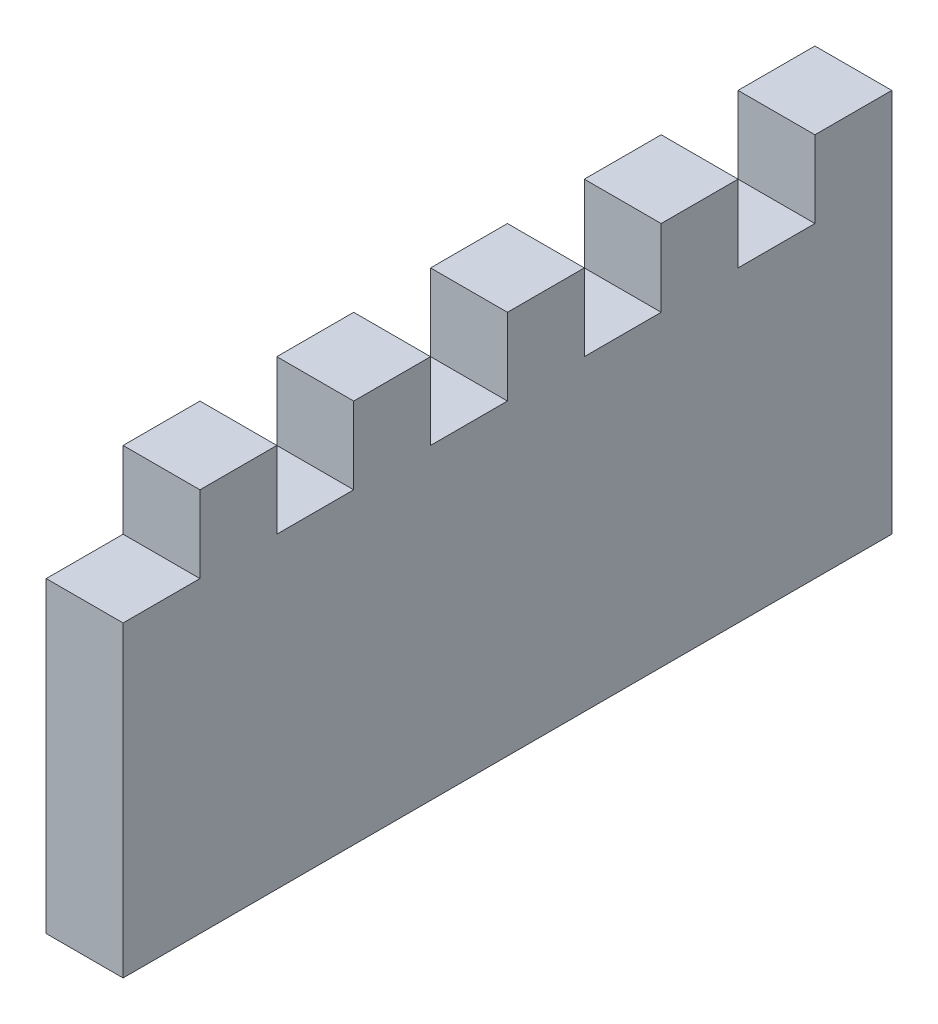
from build123d import *

# Parameters (mm, degrees)
ESQUISSE1_W                = 100
ESQUISSE1_H                = 50
BOSS_EXTRU_1_DEPTH         = 10
ESQUISSE2_W                = 10
ESQUISSE2_H                = 10
ENL_V_MAT_EXTRU_1_DEPTH    = 10
R_P_TITION_LIN_AIRE1_COUNT = 5
R_P_TITION_LIN_AIRE1_PITCH = 20


with BuildPart() as part:
    # Esquisse1 → Boss.-Extru.1 (new body)
    with BuildSketch(Plane(origin=(0, 0, 0), x_dir=(0, 0, -1), z_dir=(1, 0, 0))):
        with Locations((-50, 25)):
            Rectangle(ESQUISSE1_W, ESQUISSE1_H)
    extrude(amount=BOSS_EXTRU_1_DEPTH)

    # Esquisse2 → Enlèv. mat.-Extru.1 (cut)
    with BuildSketch(Plane(origin=(10, 0, 0), x_dir=(0, 0, -1), z_dir=(1, 0, 0))):
        with Locations((-15, 45)):
            Rectangle(ESQUISSE2_W, ESQUISSE2_H)
    enl_v_mat_extru_1 = extrude(amount=-ENL_V_MAT_EXTRU_1_DEPTH, mode=Mode.SUBTRACT)

    # Répétition linéaire1: Enlèv. mat.-Extru.1 ×5
    with Locations(*[(0, 0, i * R_P_TITION_LIN_AIRE1_PITCH) for i in range(1, R_P_TITION_LIN_AIRE1_COUNT)]):
        add(enl_v_mat_extru_1, mode=Mode.SUBTRACT)


solid = part.part
